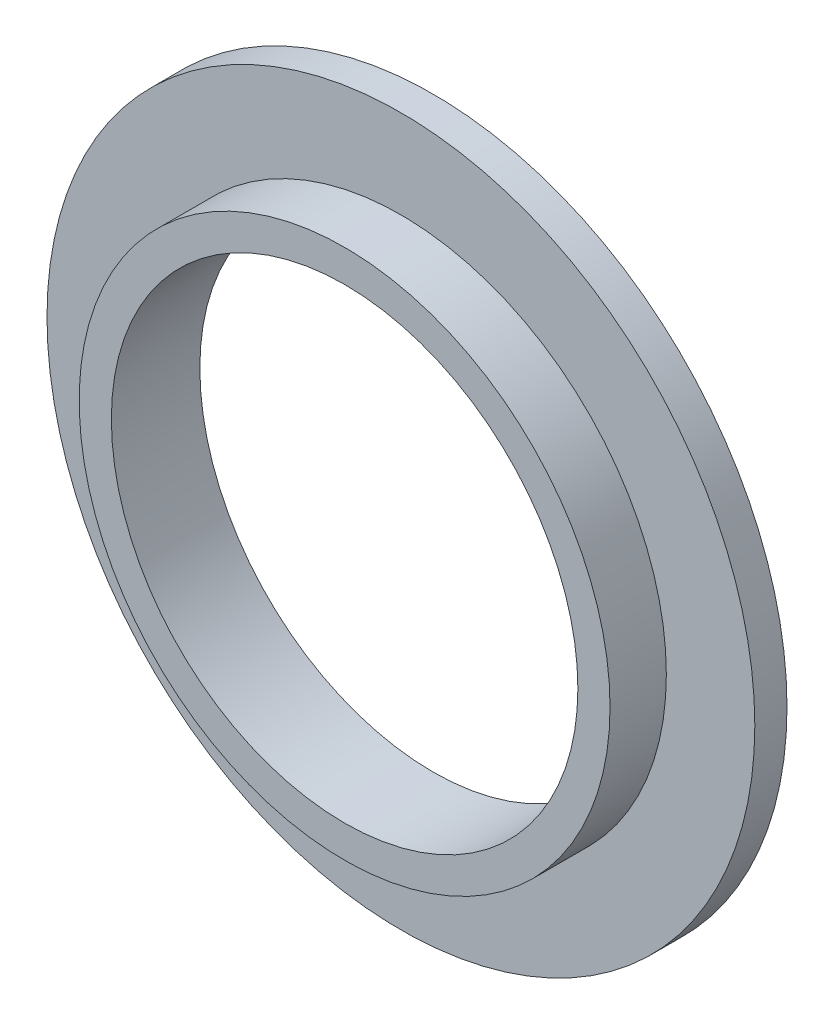
from build123d import *

# Parameters (mm, degrees)
SKETCH1_R               = 44
BOSS_EXTRUDE1_DEPTH     = 4
SKETCH2_R               = 33
BOSS_EXTRUDE2_DEPTH     = 7
SKETCH3_R               = 29
CUT_EXTRUDE1_DEPTH      = 1
CUT_EXTRUDE1_DEPTH_BACK = 12


with BuildPart() as part:
    # Sketch1 → Boss-Extrude1 (new body)
    with BuildSketch(Plane(origin=(0, 0, 0), x_dir=(0, 1, 0), z_dir=(0, 0, 1))):
        Circle(SKETCH1_R)
    extrude(amount=BOSS_EXTRUDE1_DEPTH)

    # Sketch2 → Boss-Extrude2 (add)
    with BuildSketch(Plane.XY.offset(4)):
        Circle(SKETCH2_R)
    extrude(amount=BOSS_EXTRUDE2_DEPTH)

    # Sketch3 → Cut-Extrude1 (cut, two sides)
    with BuildSketch(Plane.XY.offset(11)) as cut_extrude1_sk:
        Circle(SKETCH3_R)
    extrude(amount=CUT_EXTRUDE1_DEPTH, mode=Mode.SUBTRACT)
    extrude(cut_extrude1_sk.sketch, amount=-CUT_EXTRUDE1_DEPTH_BACK, mode=Mode.SUBTRACT)


solid = part.part
